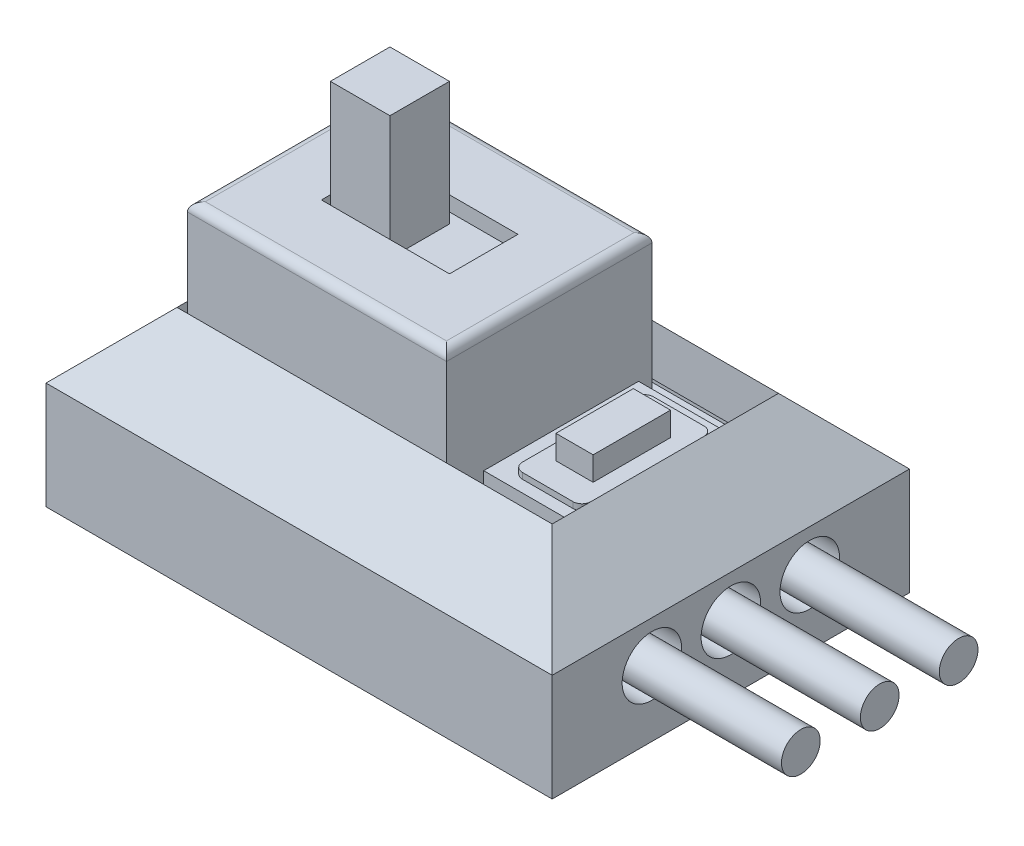
from build123d import *

# Parameters (mm, degrees)
SKIZZE1_W                            = 17
SKIZZE1_H                            = 12
AUFSATZ_LINEAR_AUSTRAGEN1_DEPTH      = 5.8
FASE1_SIZE                           = 2.2
WANDUNG1_T                           = -1.2
SCHNITT_LINEAR_AUSTRAGEN1_REACH      = 7.8
SKIZZE2_W                            = 12.6
SKIZZE2_H                            = 7.6
AUFSATZ_LINEAR_START                 = 0.5
SKIZZE3_W                            = 14.4
SKIZZE3_H                            = 9.4
AUFSATZ_LINEAR_AUSTRAGEN2_DEPTH      = 1.4
SKIZZE4_R                            = 1
SCHNITT_LINEAR_AUSTRAGEN2_DEPTH      = 1.3
SKIZZE4_3_R                          = 0.65
AUFSATZ_LINEAR_AUSTRAGEN3_DEPTH      = 5
AUFSATZ_LINEAR_AUSTRAGEN3_DEPTH_BACK = 1.3
SKIZZE5_W                            = 8.7
SKIZZE5_H                            = 6.9
SKIZZE5_W_2                          = 7.7
SKIZZE5_H_2                          = 5.9
LINEAR_AUSTRAGEN_D_NN1_DEPTH         = 5.6
AUFSATZ_LINEAR_START_2               = 5.6
SKIZZE5_3_W                          = 8.7
SKIZZE5_3_H                          = 6.9
SKIZZE5_3_W_2                        = 4.3
SKIZZE5_3_H_2                        = 2.3
SKIZZE5_3_W_3                        = 7.5
SKIZZE5_3_H_3                        = 5.7
AUFSATZ_LINEAR_AUSTRAGEN6_DEPTH      = 0.5
SKIZZE5_4_W                          = 3.5
SKIZZE5_4_H                          = 5.2
AUFSATZ_LINEAR_AUSTRAGEN7_DEPTH      = 1.9
AUFSATZ_LINEAR_START_3               = 1.9
SKIZZE5_5_W                          = 2.3
SKIZZE5_5_H                          = 4.4
AUFSATZ_LINEAR_AUSTRAGEN8_DEPTH      = 0.2
AUFSATZ_LINEAR_START_4               = 2.1
SKIZZE5_7_W                          = 1.25
SKIZZE5_7_H                          = 2.6
AUFSATZ_LINEAR_AUSTRAGEN9_DEPTH      = 0.8
SKIZZE5_9_W                          = 7.5
SKIZZE5_9_H                          = 5.7
AUFSATZ_LINEAR_AUSTRAGEN10_DEPTH     = 4.9
AUFSATZ_LINEAR_START_5               = 4.9
SKIZZE5_10_W                         = 2
SKIZZE5_10_H                         = 2
AUFSATZ_LINEAR_AUSTRAGEN11_DEPTH     = 4.15
VERRUNDUNG1_R                        = 0.3
VERRUNDUNG2_R                        = 0.3


with BuildPart() as part:
    # Skizze1 → Aufsatz-Linear austragen1 (new body)
    with BuildSketch(Plane(origin=(0, 0, 0), x_dir=(1, 0, 0), z_dir=(0, 1, 0))):
        Rectangle(SKIZZE1_W, SKIZZE1_H)
    extrude(amount=AUFSATZ_LINEAR_AUSTRAGEN1_DEPTH)

    # Fase1
    fase1_edges = [part.edges().sort_by_distance(p)[0] for p in [
        (8.5, 5.8, 0),
        (0, 5.8, -6),
        (-8.5, 5.8, 0),
        (0, 5.8, 6),
    ]]
    chamfer(fase1_edges, length=FASE1_SIZE)

    # Wandung1
    wandung1_openings = [part.faces().sort_by_distance(p)[0] for p in [
        (0, 5.8, 0),
    ]]
    offset(amount=WANDUNG1_T, openings=wandung1_openings, kind=Kind.INTERSECTION)

    # Skizze2 → Schnitt-Linear austragen1 (cut, up to next)
    with BuildSketch(Plane(origin=(0, 5.8, 0), x_dir=(1, 0, 0), z_dir=(0, 1, 0)), mode=Mode.PRIVATE) as schnitt_linear_austragen1_sk1:
        Rectangle(SKIZZE2_W, SKIZZE2_H)
    schnitt_linear_austragen1_tool1 = extrude(schnitt_linear_austragen1_sk1.sketch, amount=-SCHNITT_LINEAR_AUSTRAGEN1_REACH, mode=Mode.PRIVATE) & part.part
    add(schnitt_linear_austragen1_tool1.solids().sort_by_distance((0, 5.8, 0))[0], mode=Mode.SUBTRACT)

    # Skizze4 → Schnitt-Linear austragen2 (cut)
    with BuildSketch(Plane(origin=(8.5, 0, 0), x_dir=(0, 0, -1), z_dir=(1, 0, 0))):
        with Locations((-2.65, 2.2)):
            Circle(SKIZZE4_R)
        with Locations((0, 2.2)):
            Circle(SKIZZE4_R)
        with Locations((2.65, 2.2)):
            Circle(SKIZZE4_R)
    extrude(amount=-SCHNITT_LINEAR_AUSTRAGEN2_DEPTH, mode=Mode.SUBTRACT)


with BuildPart() as body_2:
    # Skizze3 → Aufsatz-Linear austragen2 (new body)
    with BuildSketch(Plane(origin=(0, 1.2, 0), x_dir=(1, 0, 0), z_dir=(0, 1, 0)).offset(AUFSATZ_LINEAR_START)):
        Rectangle(SKIZZE3_W, SKIZZE3_H)
    extrude(amount=AUFSATZ_LINEAR_AUSTRAGEN2_DEPTH)

    # Skizze4_3 → Aufsatz-Linear austragen3 (add, two sides)
    with BuildSketch(Plane(origin=(8.5, 0, 0), x_dir=(0, 0, -1), z_dir=(1, 0, 0))) as aufsatz_linear_austragen3_sk:
        with Locations((-2.65, 2.2)):
            Circle(SKIZZE4_3_R)
        with Locations((0, 2.2)):
            Circle(SKIZZE4_3_R)
        with Locations((2.65, 2.2)):
            Circle(SKIZZE4_3_R)
    extrude(amount=AUFSATZ_LINEAR_AUSTRAGEN3_DEPTH)
    extrude(aufsatz_linear_austragen3_sk.sketch, amount=-AUFSATZ_LINEAR_AUSTRAGEN3_DEPTH_BACK)


with BuildPart() as body_3:
    # Skizze5 → Linear-Austragen-Dünn1 (new body)
    with BuildSketch(Plane(origin=(0, 3.1, 0), x_dir=(1, 0, 0), z_dir=(0, 1, 0))):
        with Locations((-1.95, 0)):
            Rectangle(SKIZZE5_W, SKIZZE5_H)
        with Locations((-1.95, 0)):
            Rectangle(SKIZZE5_W_2, SKIZZE5_H_2, mode=Mode.SUBTRACT)
    extrude(amount=LINEAR_AUSTRAGEN_D_NN1_DEPTH)

    # Skizze5_3 → Aufsatz-Linear austragen6 (add)
    with BuildSketch(Plane(origin=(0, 3.1, 0), x_dir=(1, 0, 0), z_dir=(0, 1, 0)).offset(AUFSATZ_LINEAR_START_2)):
        with Locations((-1.95, 0)):
            Rectangle(SKIZZE5_3_W, SKIZZE5_3_H)
        with Locations((-1.95, 0)):
            Rectangle(SKIZZE5_3_W_2, SKIZZE5_3_H_2, mode=Mode.SUBTRACT)
        with Locations((-1.95, 0)):
            Rectangle(SKIZZE5_3_W_3, SKIZZE5_3_H_3)
        with Locations((-1.95, 0)):
            Rectangle(SKIZZE5_3_W_2, SKIZZE5_3_H_2, mode=Mode.SUBTRACT)
    extrude(amount=-AUFSATZ_LINEAR_AUSTRAGEN6_DEPTH)

    # Verrundung1
    verrundung1_edges = [body_3.edges().sort_by_distance(p)[0] for p in [
        (2.4, 8.7, 0),
        (-1.95, 8.7, -3.45),
        (-6.3, 8.7, 0),
        (-1.95, 8.7, 3.45),
    ]]
    fillet(verrundung1_edges, radius=VERRUNDUNG1_R)


with BuildPart() as body_4:
    # Skizze5_4 → Aufsatz-Linear austragen7 (new body)
    with BuildSketch(Plane(origin=(0, 3.1, 0), x_dir=(1, 0, 0), z_dir=(0, 1, 0))):
        with Locations((4.55, 0)):
            Rectangle(SKIZZE5_4_W, SKIZZE5_4_H)
    extrude(amount=AUFSATZ_LINEAR_AUSTRAGEN7_DEPTH)


with BuildPart() as body_5:
    # Skizze5_5 → Aufsatz-Linear austragen8 (new body)
    with BuildSketch(Plane(origin=(0, 3.1, 0), x_dir=(1, 0, 0), z_dir=(0, 1, 0)).offset(AUFSATZ_LINEAR_START_3)):
        with Locations((4.55, 0)):
            Rectangle(SKIZZE5_5_W, SKIZZE5_5_H)
    extrude(amount=AUFSATZ_LINEAR_AUSTRAGEN8_DEPTH)

    # Verrundung2
    verrundung2_edges = [body_5.edges().sort_by_distance(p)[0] for p in [
        (3.4, 5.1, 2.2),
        (3.4, 5.1, -2.2),
        (5.7, 5.1, -2.2),
        (5.7, 5.1, 2.2),
    ]]
    fillet(verrundung2_edges, radius=VERRUNDUNG2_R)


with BuildPart() as body_6:
    # Skizze5_7 → Aufsatz-Linear austragen9 (new body)
    with BuildSketch(Plane(origin=(0, 3.1, 0), x_dir=(1, 0, 0), z_dir=(0, 1, 0)).offset(AUFSATZ_LINEAR_START_4)):
        with Locations((4.55, 0)):
            Rectangle(SKIZZE5_7_W, SKIZZE5_7_H)
    extrude(amount=AUFSATZ_LINEAR_AUSTRAGEN9_DEPTH)


with BuildPart() as body_7:
    # Skizze5_9 → Aufsatz-Linear austragen10 (new body)
    with BuildSketch(Plane(origin=(0, 3.1, 0), x_dir=(1, 0, 0), z_dir=(0, 1, 0))):
        with Locations((-1.95, 0)):
            Rectangle(SKIZZE5_9_W, SKIZZE5_9_H)
    extrude(amount=AUFSATZ_LINEAR_AUSTRAGEN10_DEPTH)

    # Skizze5_10 → Aufsatz-Linear austragen11 (add)
    with BuildSketch(Plane(origin=(0, 3.1, 0), x_dir=(1, 0, 0), z_dir=(0, 1, 0)).offset(AUFSATZ_LINEAR_START_5)):
        with Locations((-2.95, 0)):
            Rectangle(SKIZZE5_10_W, SKIZZE5_10_H)
    extrude(amount=AUFSATZ_LINEAR_AUSTRAGEN11_DEPTH)


solid = Compound([part.part, body_2.part, body_3.part, body_4.part, body_5.part, body_6.part, body_7.part])
